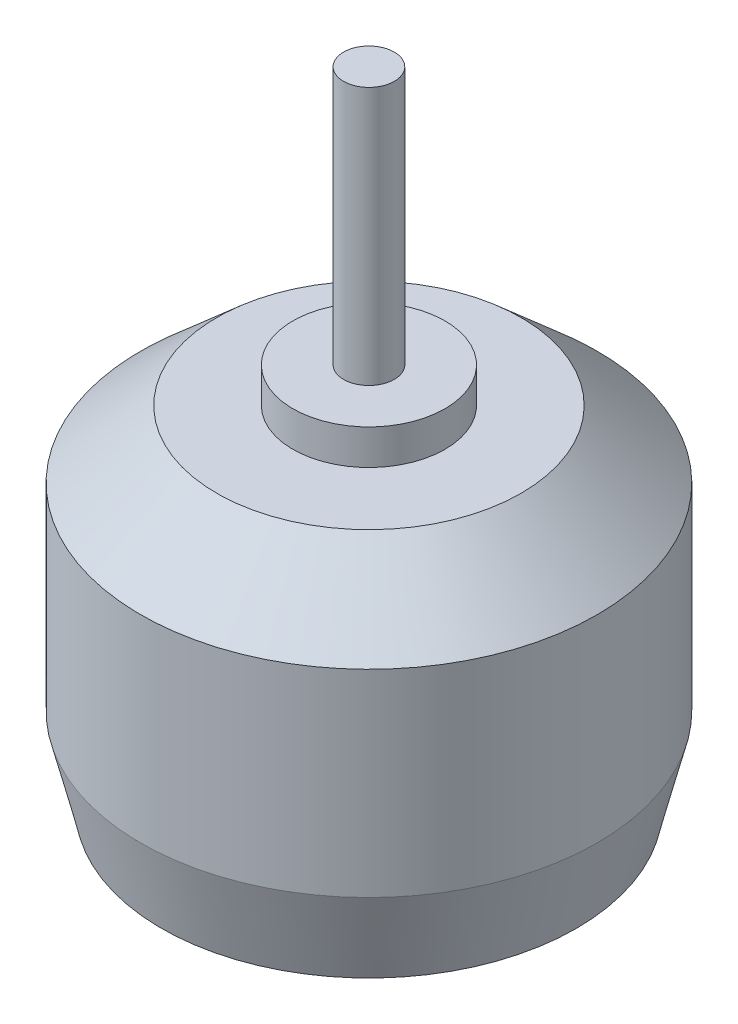
from build123d import *

# Parameters (mm, degrees)
CROQUIS3_R            = 1.25
CORTAR_EXTRUIR1_DEPTH = 5


with BuildPart() as part:
    # Croquis2 → Revolución1 (revolve)
    with BuildSketch(Plane.XY):
        Polygon((0, 19), (-1.5, 19), (-1.5, 3.734066961), (-4.5, 3.734066961), (-4.5, 1.654780276), (-9, 1.654780276), (-13.5, -2.31384669), (-13.5, -14), (-12.264104671, -19), (0, -19), align=None)
    revolve(axis=Axis((0, -19, 0), (0, 1, 0)))

    # Croquis3 → Cortar-Extruir1 (cut, symmetric)
    with BuildSketch(Plane(origin=(0, -19, 0), x_dir=(1, 0, 0), z_dir=(0, 1, 0))):
        with Locations((-9, 0)):
            Circle(CROQUIS3_R)
        with Locations((9, 0)):
            Circle(CROQUIS3_R)
        with Locations((0, -7)):
            Circle(CROQUIS3_R)
        with Locations((0, 7)):
            Circle(CROQUIS3_R)
    extrude(amount=CORTAR_EXTRUIR1_DEPTH, both=True, mode=Mode.SUBTRACT)


solid = part.part
